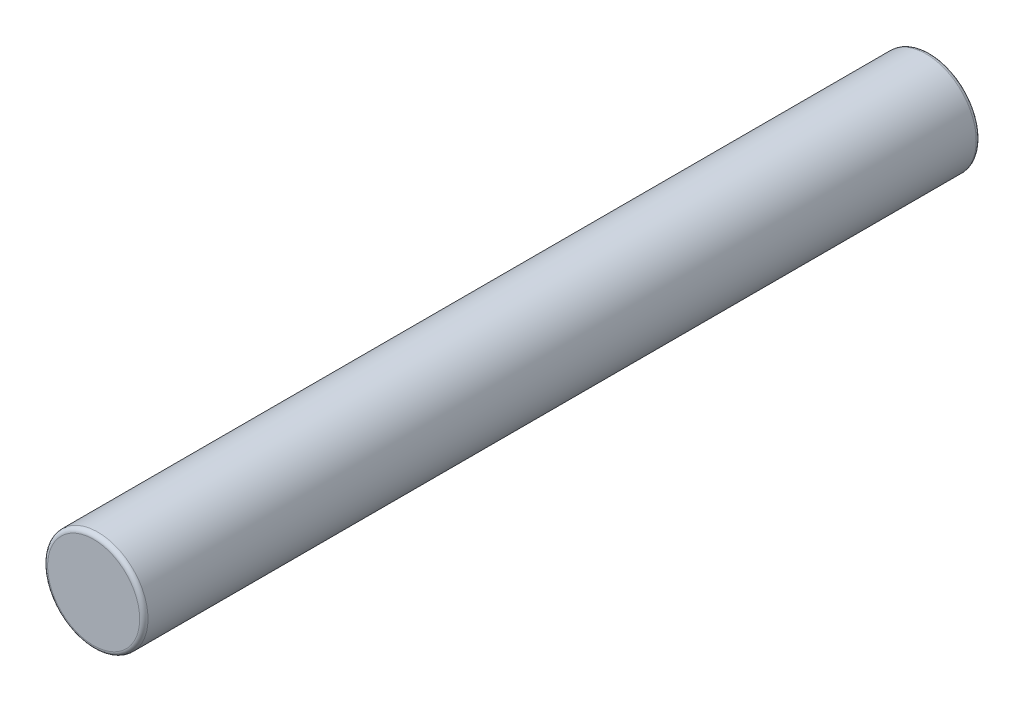
from build123d import *

# Parameters (mm, degrees)
SKETCH1_R           = 3
BOSS_EXTRUDE1_DEPTH = 50
FILLET1_R           = 0.25


with BuildPart() as part:
    # Sketch1 → Boss-Extrude1 (new body)
    with BuildSketch(Plane.XY):
        Circle(SKETCH1_R)
    extrude(amount=-BOSS_EXTRUDE1_DEPTH)

    # Fillet1
    fillet1_edges = [part.edges().sort_by_distance(p)[0] for p in [
        (-3, 0, 0),
        (-3, 0, -50),
    ]]
    fillet(fillet1_edges, radius=FILLET1_R)


solid = part.part
